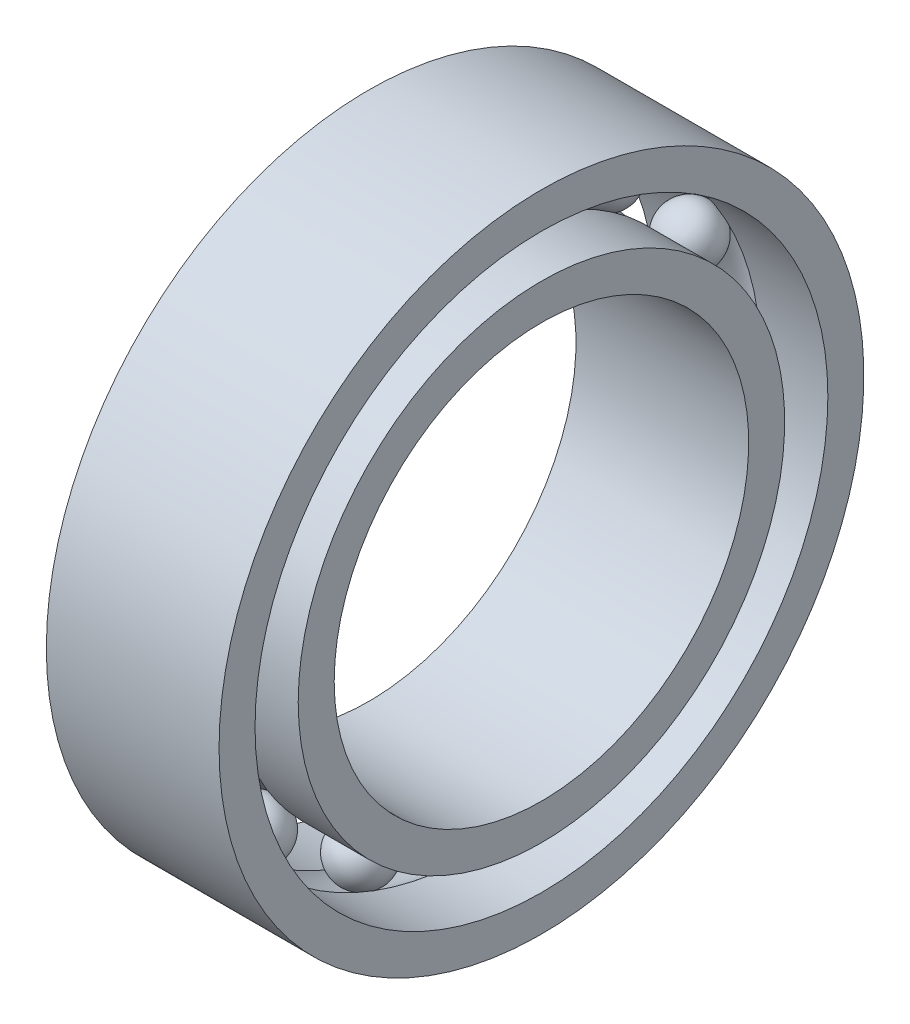
from build123d import *

# Parameters (mm, degrees)
CIRPATTERN2_COUNT = 13


with BuildPart() as part:
    # Sketch1 → Revolve2 (revolve)
    with BuildSketch(Plane(origin=(0, 0, 0), x_dir=(1, 0, 0), z_dir=(0, 1, 0))):
        with BuildLine():
            ThreePointArc((1.653594569, 21.125), (0, 20.5), (-1.653594569, 21.125))
            Line((-1.653594569, 21.125), (-7.5, 21.125))
            Line((-7.5, 21.125), (-7.5, 18))
            Line((-7.5, 18), (7.5, 18))
            Line((7.5, 18), (7.5, 21.125))
            Line((7.5, 21.125), (1.653594569, 21.125))
        make_face()
        with BuildLine():
            Line((-7.5, 28), (-7.5, 24.875))
            Line((-7.5, 24.875), (-1.653594569, 24.875))
            ThreePointArc((-1.653594569, 24.875), (0, 25.5), (1.653594569, 24.875))
            Line((1.653594569, 24.875), (7.5, 24.875))
            Line((7.5, 24.875), (7.5, 28))
            Line((7.5, 28), (-7.5, 28))
        make_face()
    revolve(axis=Axis((-1000, 0, 0), (1, 0, 0)))


with BuildPart() as body_2:
    # Sketch2 one side → Revolve3 (revolve)
    with BuildSketch(Plane(origin=(0, 0, 0), x_dir=(1, 0, 0), z_dir=(0, 1, 0))):
        with BuildLine():
            Line((-2.5, 23), (2.5, 23))
            ThreePointArc((2.5, 23), (0, 25.5), (-2.5, 23))
        make_face()
    revolve(axis=Axis((-2.5, 0, -23), (1, 0, 0)))


with BuildPart() as cirpattern2_1:
    # CirPattern2: pattern copy
    add(body_2.part.rotate(Axis((0, 0, 0), (1, 0, 0)), 1 * 360 / CIRPATTERN2_COUNT))


with BuildPart() as cirpattern2_2:
    # CirPattern2: pattern copy
    add(body_2.part.rotate(Axis((0, 0, 0), (1, 0, 0)), 2 * 360 / CIRPATTERN2_COUNT))


with BuildPart() as cirpattern2_3:
    # CirPattern2: pattern copy
    add(body_2.part.rotate(Axis((0, 0, 0), (1, 0, 0)), 3 * 360 / CIRPATTERN2_COUNT))


with BuildPart() as cirpattern2_4:
    # CirPattern2: pattern copy
    add(body_2.part.rotate(Axis((0, 0, 0), (1, 0, 0)), 4 * 360 / CIRPATTERN2_COUNT))


with BuildPart() as cirpattern2_5:
    # CirPattern2: pattern copy
    add(body_2.part.rotate(Axis((0, 0, 0), (1, 0, 0)), 5 * 360 / CIRPATTERN2_COUNT))


with BuildPart() as cirpattern2_6:
    # CirPattern2: pattern copy
    add(body_2.part.rotate(Axis((0, 0, 0), (1, 0, 0)), 6 * 360 / CIRPATTERN2_COUNT))


with BuildPart() as cirpattern2_7:
    # CirPattern2: pattern copy
    add(body_2.part.rotate(Axis((0, 0, 0), (1, 0, 0)), 7 * 360 / CIRPATTERN2_COUNT))


with BuildPart() as cirpattern2_8:
    # CirPattern2: pattern copy
    add(body_2.part.rotate(Axis((0, 0, 0), (1, 0, 0)), 8 * 360 / CIRPATTERN2_COUNT))


with BuildPart() as cirpattern2_9:
    # CirPattern2: pattern copy
    add(body_2.part.rotate(Axis((0, 0, 0), (1, 0, 0)), 9 * 360 / CIRPATTERN2_COUNT))


with BuildPart() as cirpattern2_10:
    # CirPattern2: pattern copy
    add(body_2.part.rotate(Axis((0, 0, 0), (1, 0, 0)), 10 * 360 / CIRPATTERN2_COUNT))


with BuildPart() as cirpattern2_11:
    # CirPattern2: pattern copy
    add(body_2.part.rotate(Axis((0, 0, 0), (1, 0, 0)), 11 * 360 / CIRPATTERN2_COUNT))


with BuildPart() as cirpattern2_12:
    # CirPattern2: pattern copy
    add(body_2.part.rotate(Axis((0, 0, 0), (1, 0, 0)), 12 * 360 / CIRPATTERN2_COUNT))


solid = Compound([part.part, body_2.part, cirpattern2_1.part, cirpattern2_2.part, cirpattern2_3.part, cirpattern2_4.part, cirpattern2_5.part, cirpattern2_6.part, cirpattern2_7.part, cirpattern2_8.part, cirpattern2_9.part, cirpattern2_10.part, cirpattern2_11.part, cirpattern2_12.part])
